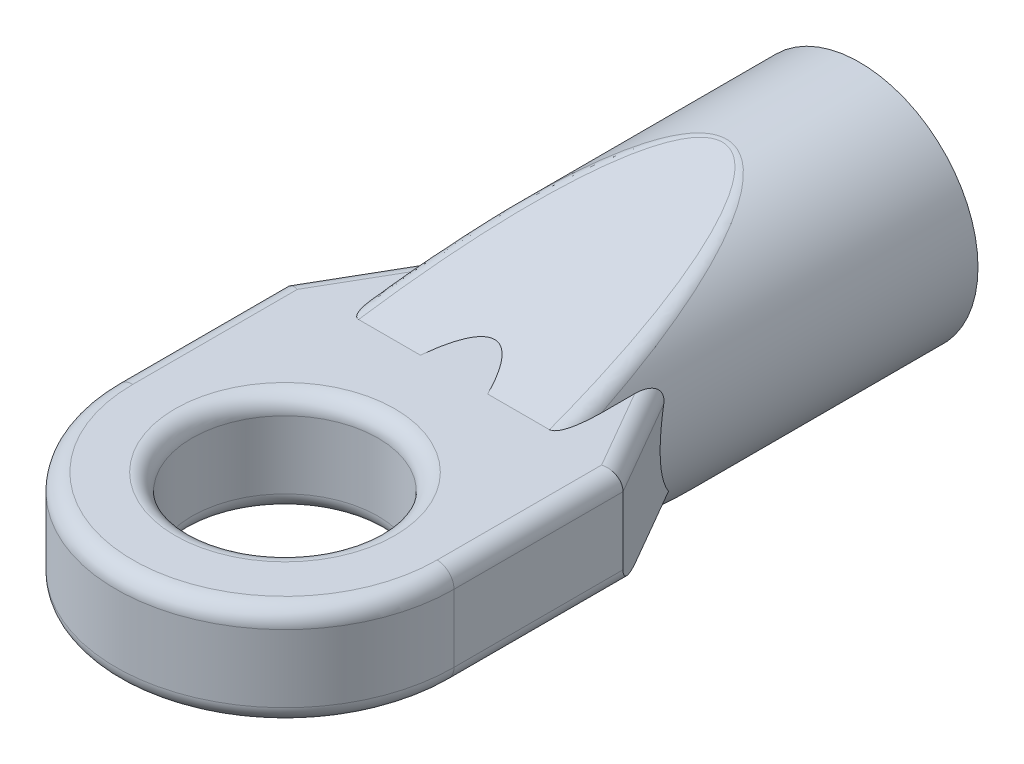
from build123d import *

# Parameters (mm, degrees)
SKETCH1_R           = 3.5
SKETCH1_R_2         = 1.8
BOSS_EXTRUDE1_DEPTH = 12
BOSS_EXTRUDE2_DEPTH = 1.5
BOSS_EXTRUDE3_DEPTH = 1.5
CUT_EXTRUDE1_DEPTH  = 5
SKETCH6_R           = 2.75
CUT_EXTRUDE2_DEPTH  = 6
FILLET1_R           = 0.5


with BuildPart() as part:
    # Sketch1 → Boss-Extrude1 (new body)
    with BuildSketch(Plane.XY):
        Circle(SKETCH1_R)
        Circle(SKETCH1_R_2, mode=Mode.SUBTRACT)
    extrude(amount=BOSS_EXTRUDE1_DEPTH)

    # Sketch2 → Boss-Extrude2 (add, symmetric)
    with BuildSketch(Plane(origin=(0, 0, 0), x_dir=(1, 0, 0), z_dir=(0, 1, 0))):
        with BuildLine():
            Line((-5, -17), (-5, -12))
            Line((-5, -12), (5, -12))
            Line((5, -12), (5, -17))
            ThreePointArc((5, -17), (0, -22), (-5, -17))
        make_face()
    extrude(amount=BOSS_EXTRUDE2_DEPTH, both=True)

    # Sketch3 → Boss-Extrude3 (add, symmetric)
    with BuildSketch(Plane(origin=(0, 0, 0), x_dir=(1, 0, 0), z_dir=(0, 1, 0))):
        Polygon((5, -12), (0, -3.339745962), (-5, -12), align=None)
    extrude(amount=BOSS_EXTRUDE3_DEPTH, both=True)

    # Sketch5 → Cut-Extrude1 (cut, symmetric)
    with BuildSketch(Plane(origin=(0, 0, 0), x_dir=(0, 0, -1), z_dir=(1, 0, 0))):
        Polygon((-12, 1.5), (-4, 3.5), (-12, 3.5), align=None)
    cut_extrude1 = extrude(amount=CUT_EXTRUDE1_DEPTH, both=True, mode=Mode.SUBTRACT)

    # Mirror1: Cut-Extrude1 across plane
    add(cut_extrude1.mirror(Plane.ZX), mode=Mode.SUBTRACT)

    # Sketch6 → Cut-Extrude2 (cut, through all)
    with BuildSketch(Plane(origin=(0, 1.5, 0), x_dir=(1, 0, 0), z_dir=(0, 1, 0))):
        with Locations((0, -17)):
            Circle(SKETCH6_R)
    extrude(amount=-CUT_EXTRUDE2_DEPTH, mode=Mode.SUBTRACT)

    # Fillet1
    fillet1_edges = [part.edges().sort_by_distance(p)[0] for p in [
        (-5, -1.5, 14.5),
        (0, -1.5, 22),
        (-5, 1.5, 14.5),
        (5, 1.5, 14.5),
        (-2.342808298, 2.600240235, 7.599039061),
        (2.342808298, -2.600240235, 7.599039061),
        (-4.08113883, 1.5, 10.408485769),
        (-4.08113883, -1.5, 10.408485769),
        (5, -1.5, 14.5),
        (-2.75, -1.5, 17),
        (-2.75, 1.5, 17),
        (4.08113883, 1.5, 10.408485769),
        (0, 1.5, 22),
    ]]
    fillet(fillet1_edges, radius=FILLET1_R)


solid = part.part
